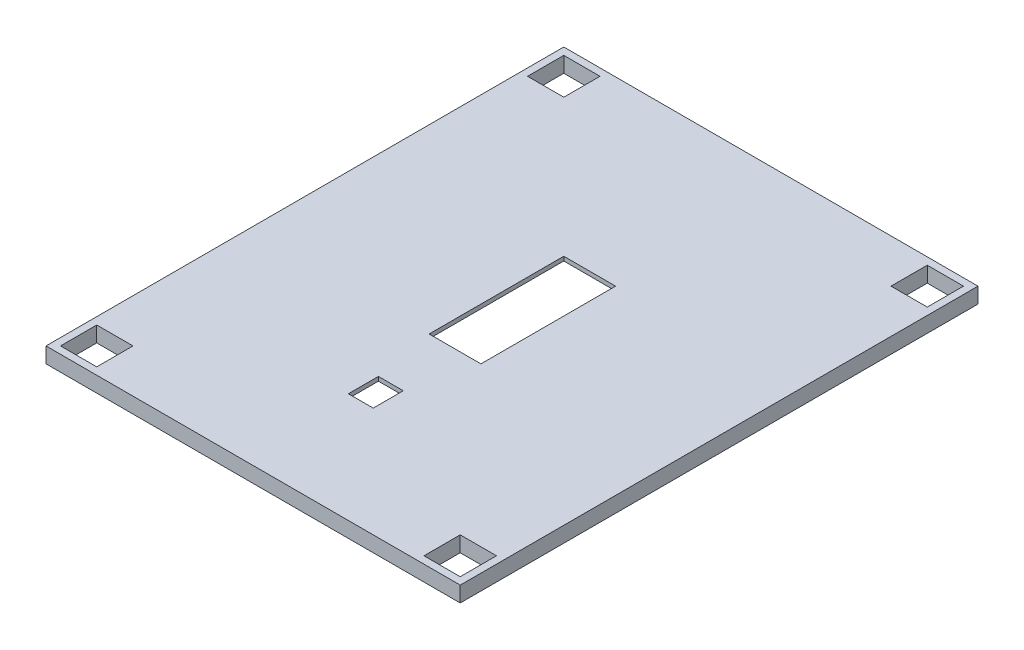
from build123d import *

# Parameters (mm, degrees)
SKETCH1_W           = 80
SKETCH1_H           = 100
BOSS_EXTRUDE1_DEPTH = 3
SKETCH2_W           = 76.8
SKETCH2_H           = 96.8
CUT_EXTRUDE1_DEPTH  = 2.2
CUT_EXTRUDE2_REACH  = 5
SKETCH5_W           = 10
SKETCH5_H           = 26
SKETCH5_W_2         = 4.8
SKETCH5_H_2         = 5.8
SKETCH7_W           = 5.5
SKETCH7_H           = 2.2
CUT_EXTRUDE4_DEPTH  = 3
SKETCH9_W           = 8.2
SKETCH9_H           = 8.2
BOSS_EXTRUDE2_DEPTH = 2.2
SKETCH10_W          = 7
SKETCH10_H          = 7
CUT_EXTRUDE5_DEPTH  = 4


with BuildPart() as part:
    # Sketch1 → Boss-Extrude1 (new body)
    with BuildSketch(Plane(origin=(0, 0, 0), x_dir=(1, 0, 0), z_dir=(0, 1, 0))):
        with Locations((40, 50)):
            Rectangle(SKETCH1_W, SKETCH1_H)
    extrude(amount=BOSS_EXTRUDE1_DEPTH)

    # Sketch2 → Cut-Extrude1 (cut)
    with BuildSketch(Plane.XZ):
        with Locations((40, -50)):
            Rectangle(SKETCH2_W, SKETCH2_H)
    extrude(amount=-CUT_EXTRUDE1_DEPTH, mode=Mode.SUBTRACT)

    # Sketch5 → Cut-Extrude2 (cut, up to next)
    with BuildSketch(Plane(origin=(0, 3, 0), x_dir=(1, 0, 0), z_dir=(0, 1, 0)), mode=Mode.PRIVATE) as cut_extrude2_sk1:
        with Locations((40, 52)):
            Rectangle(SKETCH5_W, SKETCH5_H)
    cut_extrude2_tool1 = extrude(cut_extrude2_sk1.sketch, amount=-CUT_EXTRUDE2_REACH, mode=Mode.PRIVATE) & part.part
    add(cut_extrude2_tool1.solids().sort_by_distance((40, 3, -52))[0], mode=Mode.SUBTRACT)
    # Sketch5 → Cut-Extrude2 (cut, up to next)
    with BuildSketch(Plane(origin=(0, 3, 0), x_dir=(1, 0, 0), z_dir=(0, 1, 0)), mode=Mode.PRIVATE) as cut_extrude2_sk2:
        with Locations((39.6, 24.1)):
            Rectangle(SKETCH5_W_2, SKETCH5_H_2)
    cut_extrude2_tool2 = extrude(cut_extrude2_sk2.sketch, amount=-CUT_EXTRUDE2_REACH, mode=Mode.PRIVATE) & part.part
    add(cut_extrude2_tool2.solids().sort_by_distance((39.6, 3, -24.1))[0], mode=Mode.SUBTRACT)

    # Sketch7 → Cut-Extrude4 (cut)
    with BuildSketch(Plane(origin=(0, 0, -100), x_dir=(-1, 0, 0), z_dir=(0, 0, -1))):
        with Locations((-40, 1.1)):
            Rectangle(SKETCH7_W, SKETCH7_H)
    extrude(amount=-CUT_EXTRUDE4_DEPTH, mode=Mode.SUBTRACT)

    # Sketch9 → Boss-Extrude2 (add)
    with BuildSketch(Plane.XZ.offset(-2.2)):
        with Locations((5.7, -5.7)):
            Rectangle(SKETCH9_W, SKETCH9_H)
        with Locations((74.3, -5.7)):
            Rectangle(SKETCH9_W, SKETCH9_H)
        with Locations((5.7, -94.3)):
            Rectangle(SKETCH9_W, SKETCH9_H)
        with Locations((74.3, -94.3)):
            Rectangle(SKETCH9_W, SKETCH9_H)
    extrude(amount=BOSS_EXTRUDE2_DEPTH)

    # Sketch10 → Cut-Extrude5 (cut, through all)
    with BuildSketch(Plane.XZ):
        with Locations((4.9, -4.9)):
            Rectangle(SKETCH10_W, SKETCH10_H)
        with Locations((4.9, -95.1)):
            Rectangle(SKETCH10_W, SKETCH10_H)
        with Locations((75.1, -95.1)):
            Rectangle(SKETCH10_W, SKETCH10_H)
        with Locations((75.1, -4.9)):
            Rectangle(SKETCH10_W, SKETCH10_H)
    extrude(amount=-CUT_EXTRUDE5_DEPTH, mode=Mode.SUBTRACT)


solid = part.part
